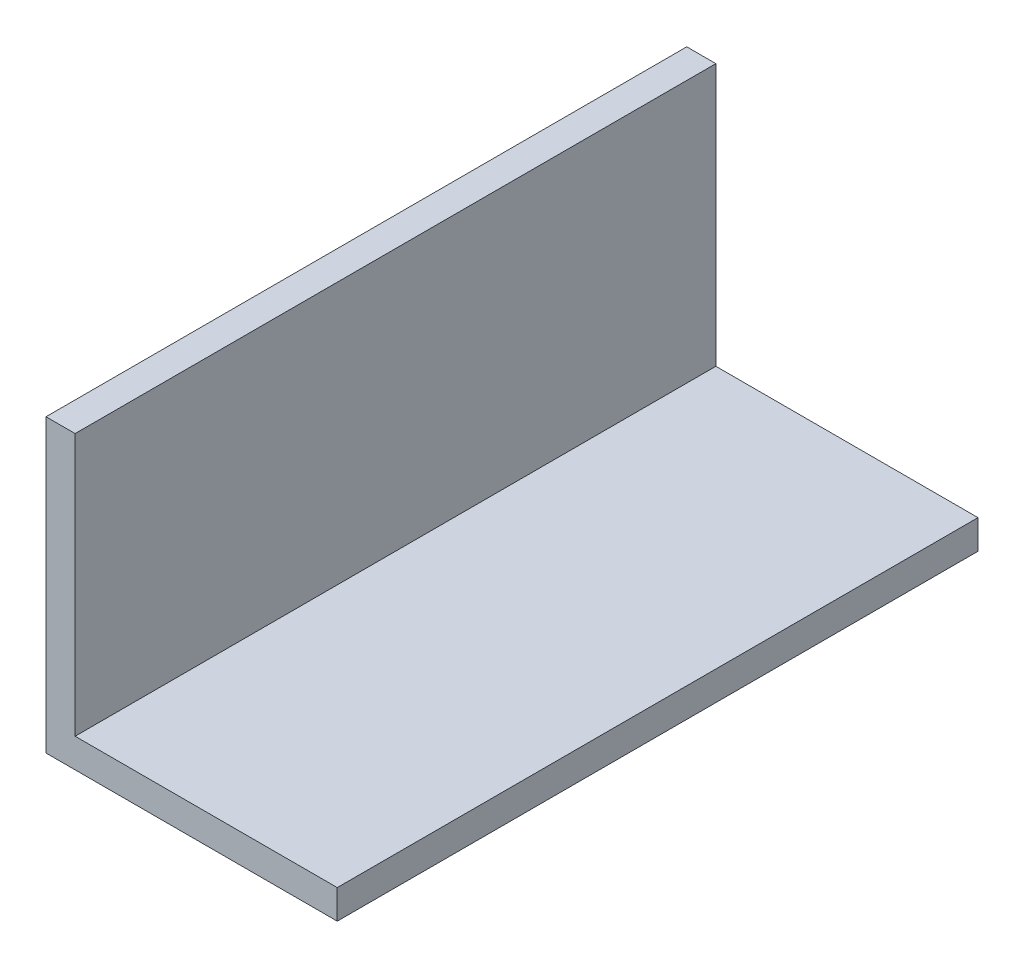
from build123d import *

# Parameters (mm, degrees)
EXTRUDE_1_DEPTH = 66


with BuildPart() as part:
    # Эскиз1 → Бобышка-Вытянуть1 (new body)
    with BuildSketch(Plane.XY):
        Polygon((0, 30), (0, 0), (30, 0), (30, 3), (3, 3), (3, 30), align=None)
    extrude(amount=EXTRUDE_1_DEPTH)


solid = part.part
